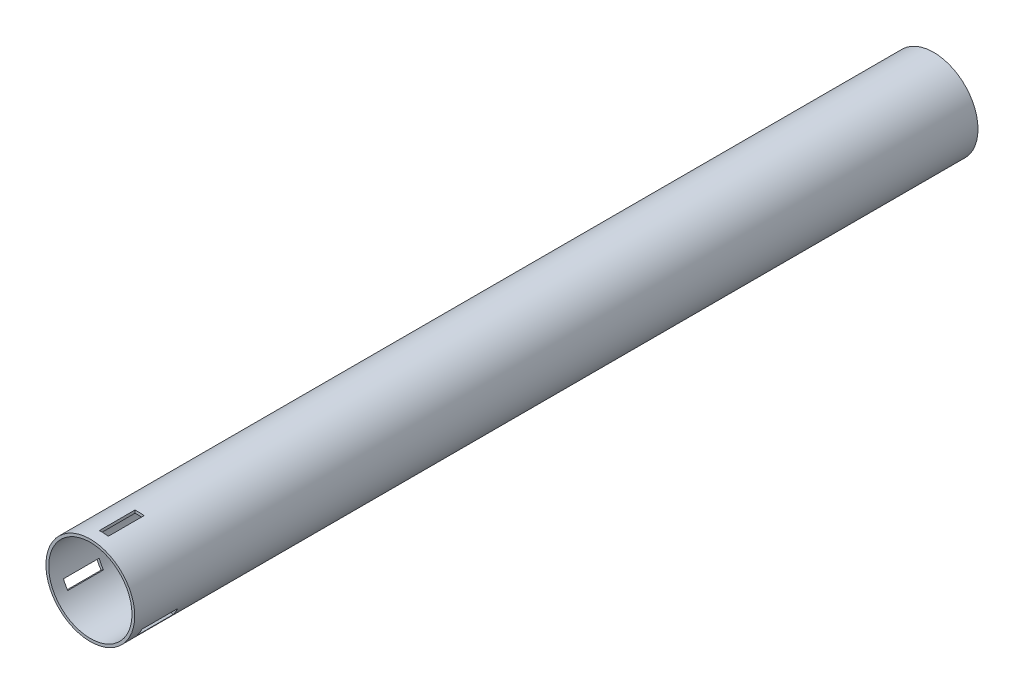
from build123d import *

# Parameters (mm, degrees)
SKETCH1_R           = 23.6982
SKETCH1_R_2         = 22.225
BOSS_EXTRUDE1_DEPTH = 450
CUT_EXTRUDE2_START  = -28.81672
SKETCH3_W           = 4.856446364
SKETCH3_H           = 19.05
CUT_EXTRUDE2_DEPTH  = 1.71492
CIRPATTERN4_COUNT   = 3


with BuildPart() as part:
    # Sketch1 → Boss-Extrude1 (new body)
    with BuildSketch(Plane.XY):
        Circle(SKETCH1_R)
        Circle(SKETCH1_R_2, mode=Mode.SUBTRACT)
    extrude(amount=BOSS_EXTRUDE1_DEPTH)

    # Sketch3 → Cut-Extrude2 (cut)
    with BuildSketch(Plane(origin=(0, 50.8, 0), x_dir=(1, 0, 0), z_dir=(0, 1, 0)).offset(CUT_EXTRUDE2_START)):
        with Locations((0.840723182, -434.125)):
            Rectangle(SKETCH3_W, SKETCH3_H)
    cut_extrude2 = extrude(amount=CUT_EXTRUDE2_DEPTH, mode=Mode.SUBTRACT)

    # CirPattern4: Cut-Extrude2 ×3 about axis
    cirpattern4_axis = Axis((0, 0, 0), (0, 0, 1))
    for i in range(1, CIRPATTERN4_COUNT):
        add(cut_extrude2.rotate(cirpattern4_axis, i * 360 / CIRPATTERN4_COUNT), mode=Mode.SUBTRACT)


solid = part.part
